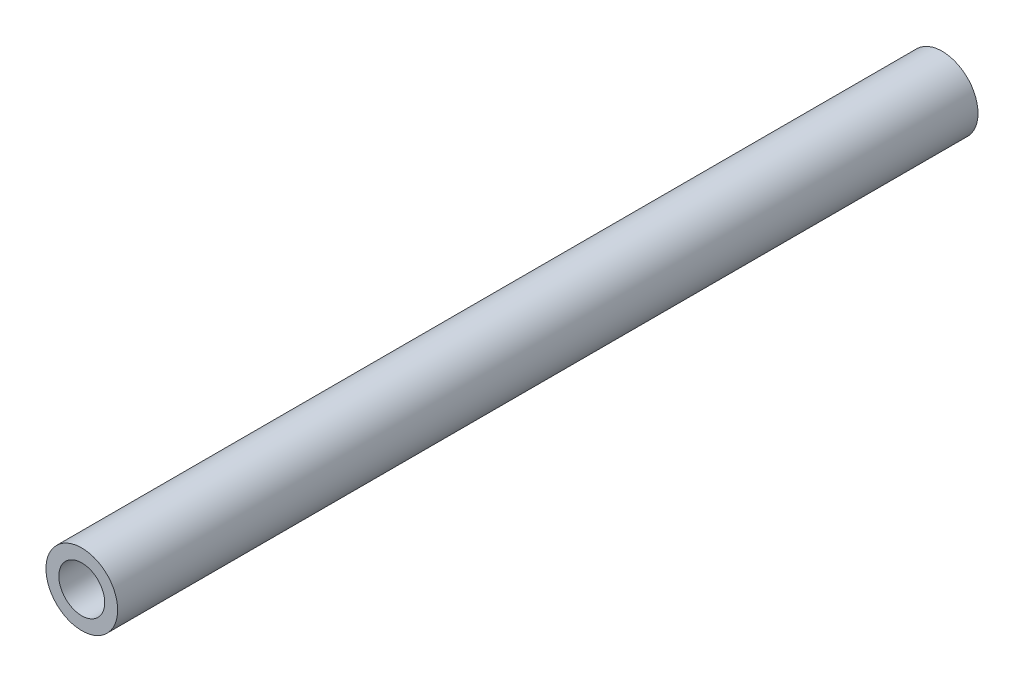
from build123d import *

# Parameters (mm, degrees)
SKETCH1_R           = 2.5
SKETCH1_R_2         = 1.6
BOSS_EXTRUDE1_DEPTH = 60


with BuildPart() as part:
    # Sketch1 → Boss-Extrude1 (new body)
    with BuildSketch(Plane.XY):
        Circle(SKETCH1_R)
        Circle(SKETCH1_R_2, mode=Mode.SUBTRACT)
    extrude(amount=BOSS_EXTRUDE1_DEPTH)


solid = part.part
